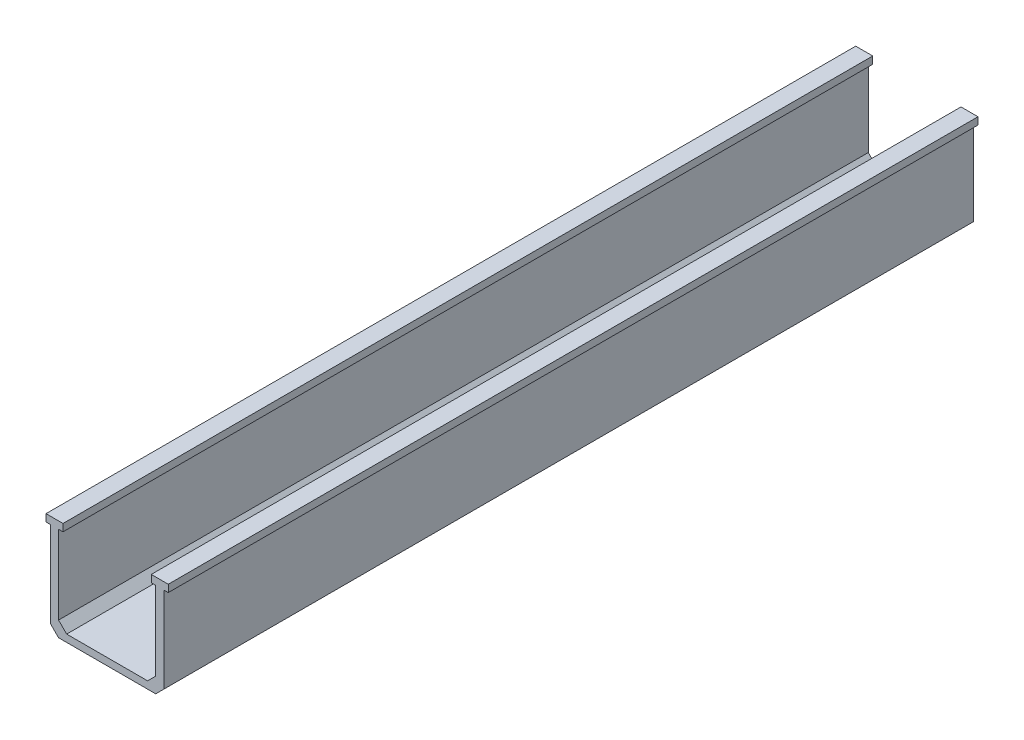
from build123d import *

# Parameters (mm, degrees)
BOSS_EXTRU_1_DEPTH           = 200
CHANFREIN1_SIZE              = 2
ESQUISSE2_R                  = 3
ENL_V_MAT_EXTRU_1_DEPTH      = 1
ENL_V_MAT_EXTRU_1_DEPTH_BACK = 26
CHANFREIN2_SIZE              = 2
CHANFREIN3_SIZE              = 2


with BuildPart() as part:
    # Esquisse1 → Boss.-Extru.1 (new body)
    with BuildSketch(Plane.XY):
        Polygon((-14, 10.714285714), (-14, -12.5), (14, -12.5), (14, 10.714285714), (15.100215679, 10.714285714), (15.100215679, 12.5), (14, 12.5), (10.899784321, 12.5), (10.899784321, 10.714285714), (12, 10.714285714), (12, -10.714285714), (-12, -10.714285714), (-12, 10.714285714), (-10.899784321, 10.714285714), (-10.899784321, 12.5), (-14, 12.5), (-15.100215679, 12.5), (-15.100215679, 10.714285714), align=None)
    extrude(amount=BOSS_EXTRU_1_DEPTH)

    # Chanfrein1
    chanfrein1_edges = [part.edges().sort_by_distance(p)[0] for p in [
        (14, -12.5, 100),
        (-14, -12.5, 100),
    ]]
    chamfer(chanfrein1_edges, length=CHANFREIN1_SIZE)

    # Esquisse2 → Enlèv. mat.-Extru.1 (cut, two sides)
    with BuildSketch(Plane.XZ.offset(12.5)) as enl_v_mat_extru_1_sk:
        with Locations((0, 100)):
            Circle(ESQUISSE2_R)
        with Locations((0, 175.000381003)):
            Circle(ESQUISSE2_R)
        with Locations((0, 24.999618997)):
            Circle(ESQUISSE2_R)
    extrude(amount=ENL_V_MAT_EXTRU_1_DEPTH, mode=Mode.SUBTRACT)
    extrude(enl_v_mat_extru_1_sk.sketch, amount=-ENL_V_MAT_EXTRU_1_DEPTH_BACK, mode=Mode.SUBTRACT)

    # Chanfrein2
    chanfrein2_edges = [part.edges().sort_by_distance(p)[0] for p in [
        (-12, -10.714285714, 100),
    ]]
    chamfer(chanfrein2_edges, length=CHANFREIN2_SIZE)

    # Chanfrein3
    chanfrein3_edges = [part.edges().sort_by_distance(p)[0] for p in [
        (12, -10.714285714, 100),
    ]]
    chamfer(chanfrein3_edges, length=CHANFREIN3_SIZE)


solid = part.part
